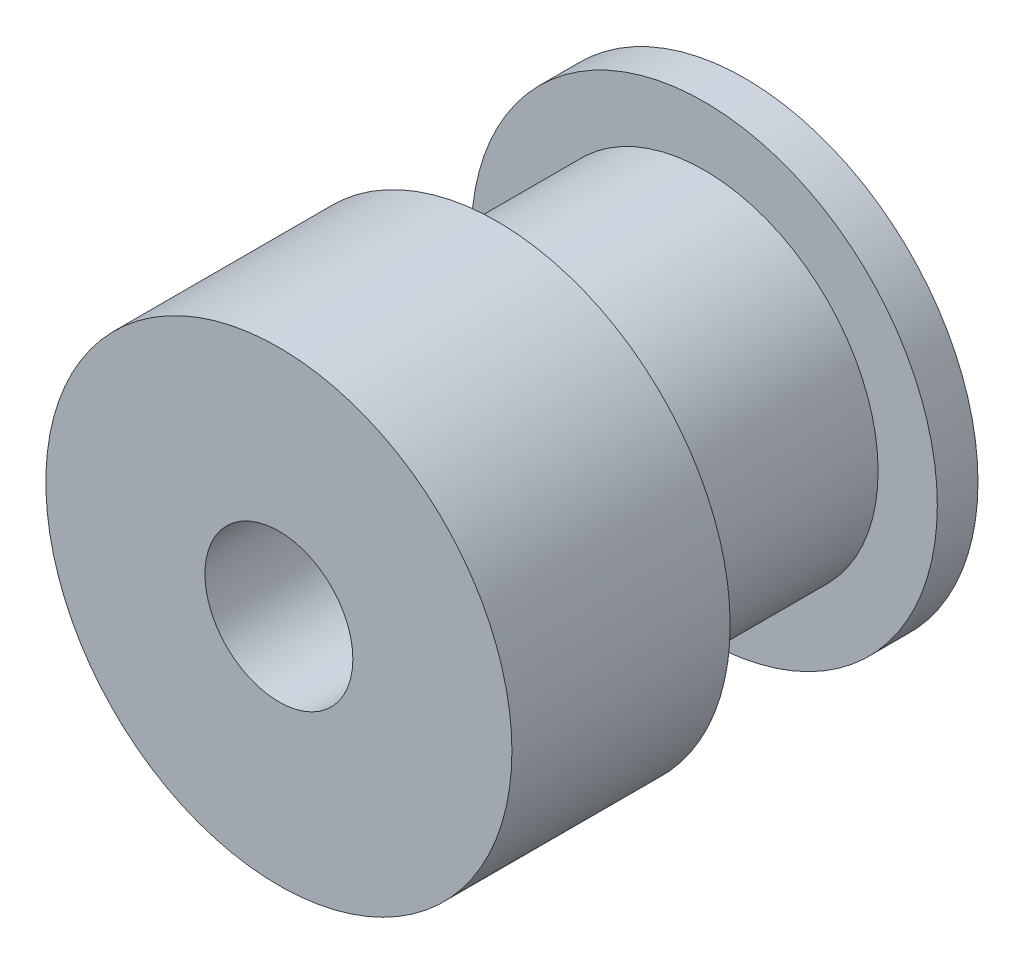
from build123d import *


with BuildPart() as part:
    # Sketch2 → Revolve1 (revolve)
    with BuildSketch(Plane(origin=(0, 0, 0), x_dir=(1, 0, 0), z_dir=(0, 1, 0))):
        Polygon((2.54, 0), (2.54, 16.002), (8.001, 16.002), (8.001, 14.605), (5.969, 14.605), (5.969, 7.493), (8.001, 7.493), (8.001, 0), align=None)
    revolve(axis=Axis((0, 0, 0.169544175), (0, 0, -1)))


solid = part.part
